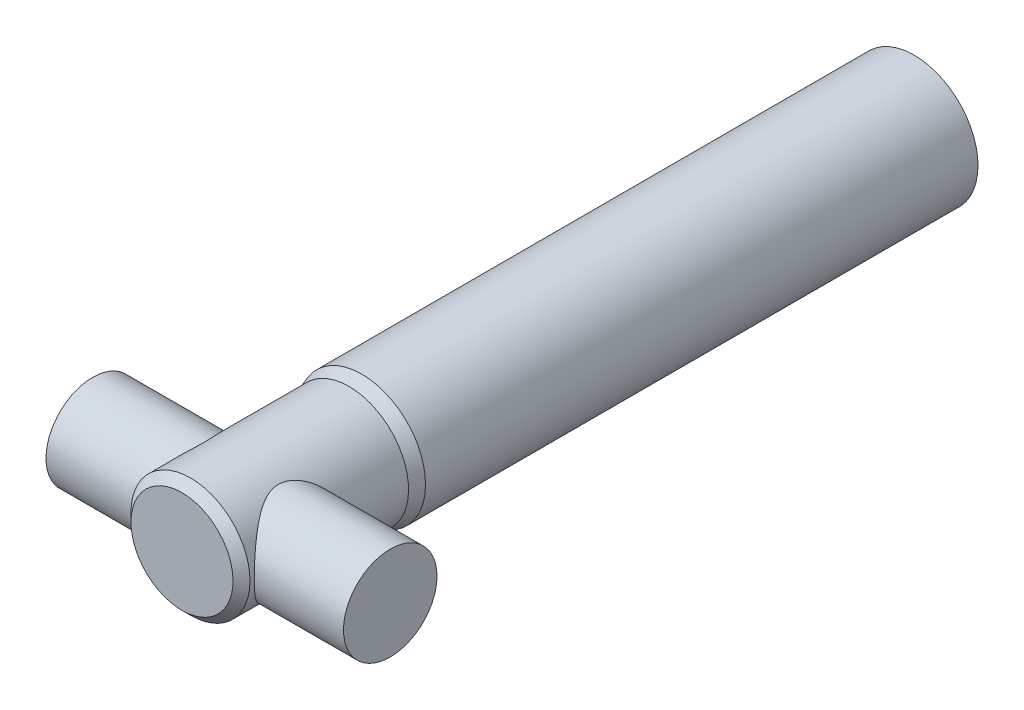
from build123d import *

# Parameters (mm, degrees)
SKETCH2_R           = 15
BOSS_EXTRUDE2_DEPTH = 130
SKETCH5_R           = 11
BOSS_EXTRUDE3_DEPTH = 35
CHAMFER1_SIZE       = 2


with BuildPart() as part:
    # Sketch2 → Boss-Extrude2 (new body)
    with BuildSketch(Plane.XY):
        Circle(SKETCH2_R)
    extrude(amount=BOSS_EXTRUDE2_DEPTH)

    # Sketch4 → Revolve1 (revolve)
    with BuildSketch(Plane(origin=(0, 0, 0), x_dir=(0, 0, -1), z_dir=(1, 0, 0))):
        Polygon((-130, 0), (-172.3, 0), (-172.3, 14), (-133, 14), (-130, 15), align=None)
    revolve(axis=Axis((0, 0, 130), (0, 0, 1)))

    # Sketch5 → Boss-Extrude3 (add, symmetric)
    with BuildSketch(Plane(origin=(0, 0, 0), x_dir=(0, 0, -1), z_dir=(1, 0, 0))):
        with Locations((-158.3, 0)):
            Circle(SKETCH5_R)
    extrude(amount=BOSS_EXTRUDE3_DEPTH, both=True)

    # Chamfer1
    chamfer1_edges = [part.edges().sort_by_distance(p)[0] for p in [
        (0, -14, 172.3),
    ]]
    chamfer(chamfer1_edges, length=CHAMFER1_SIZE)


solid = part.part
